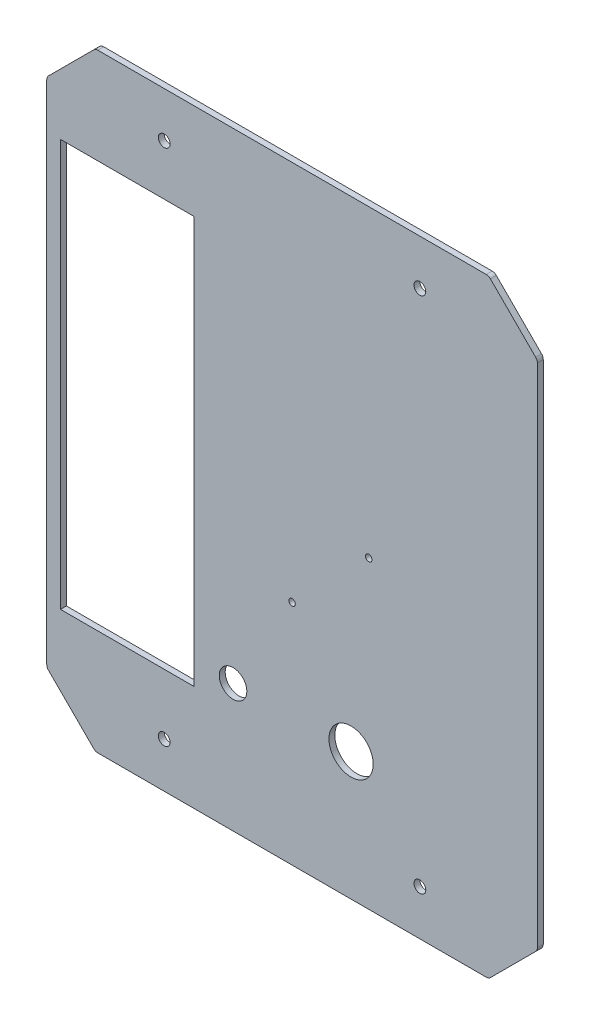
from build123d import *

# Parameters (mm, degrees)
BASE_DEPTH                     = 3
CONG_1_R                       = 3
ESQUISSE20_R                   = 3
PER_AGE_PROFIL_S_DEPTH         = 4
ESQUISSE21_R                   = 1.65
PER_AGE_LIDAR_DEPTH            = 4
ESQUISSE22_R                   = 11.25
PER_AGE_ARRET_D_URGENCE_DEPTH  = 4
ESQUISSE23_R                   = 7
PER_AGE_TIRETTE_DEPTH          = 4
ESQUISSE24_W                   = 68
ESQUISSE24_H                   = 207
PER_AGE_CABLE_MANAGEMENT_DEPTH = 4


with BuildPart() as part:
    # Esquisse1 → Base (new body)
    with BuildSketch(Plane.XY):
        Polygon((0, 0), (-200, 0), (-224.748737342, 24.748737342), (-224.748737342, 284.748737342), (-200, 309.497474683), (0, 309.497474683), (24.748737342, 284.748737342), (24.748737342, 24.748737342), align=None)
    extrude(amount=BASE_DEPTH)

    # Congé1
    cong_1_edges = [part.edges().sort_by_distance(p)[0] for p in [
        (0, 0, 1.5),
        (-200, 0, 1.5),
        (-224.748737342, 24.748737342, 1.5),
        (-224.748737342, 284.748737342, 1.5),
        (-200, 309.497474683, 1.5),
        (0, 309.497474683, 1.5),
        (24.748737342, 284.748737342, 1.5),
        (24.748737342, 24.748737342, 1.5),
    ]]
    fillet(cong_1_edges, radius=CONG_1_R)

    # Esquisse20 → Perçage Profilés (cut, through all)
    with BuildSketch(Plane(origin=(0, 0, 0), x_dir=(-1, 0, 0), z_dir=(0, 0, -1))):
        with Locations((35, 286.497474683)):
            Circle(ESQUISSE20_R)
        with Locations((165, 286.497474683)):
            Circle(ESQUISSE20_R)
        with Locations((165, 23)):
            Circle(ESQUISSE20_R)
        with Locations((35, 23)):
            Circle(ESQUISSE20_R)
    extrude(amount=-PER_AGE_PROFIL_S_DEPTH, mode=Mode.SUBTRACT)

    # Esquisse21 → Perçage Lidar (cut, through all)
    with BuildSketch(Plane(origin=(0, 0, 0), x_dir=(-1, 0, 0), z_dir=(0, 0, -1))):
        with Locations((61, 154.748737342)):
            Circle(ESQUISSE21_R)
        with Locations((100, 115.748737342)):
            Circle(ESQUISSE21_R)
    extrude(amount=-PER_AGE_LIDAR_DEPTH, mode=Mode.SUBTRACT)

    # Esquisse22 → Perçage Arret d'urgence (cut, through all)
    with BuildSketch(Plane(origin=(0, 0, 0), x_dir=(-1, 0, 0), z_dir=(0, 0, -1))):
        with Locations((70, 65)):
            Circle(ESQUISSE22_R)
    extrude(amount=-PER_AGE_ARRET_D_URGENCE_DEPTH, mode=Mode.SUBTRACT)

    # Esquisse23 → Perçage Tirette (cut, through all)
    with BuildSketch(Plane(origin=(0, 0, 0), x_dir=(-1, 0, 0), z_dir=(0, 0, -1))):
        with Locations((130, 65)):
            Circle(ESQUISSE23_R)
    extrude(amount=-PER_AGE_TIRETTE_DEPTH, mode=Mode.SUBTRACT)

    # Esquisse24 → Perçage Cable management (cut, through all)
    with BuildSketch(Plane(origin=(0, 0, 0), x_dir=(-1, 0, 0), z_dir=(0, 0, -1))):
        with Locations((183.744364822, 157.241556094)):
            Rectangle(ESQUISSE24_W, ESQUISSE24_H)
    extrude(amount=-PER_AGE_CABLE_MANAGEMENT_DEPTH, mode=Mode.SUBTRACT)


solid = part.part
